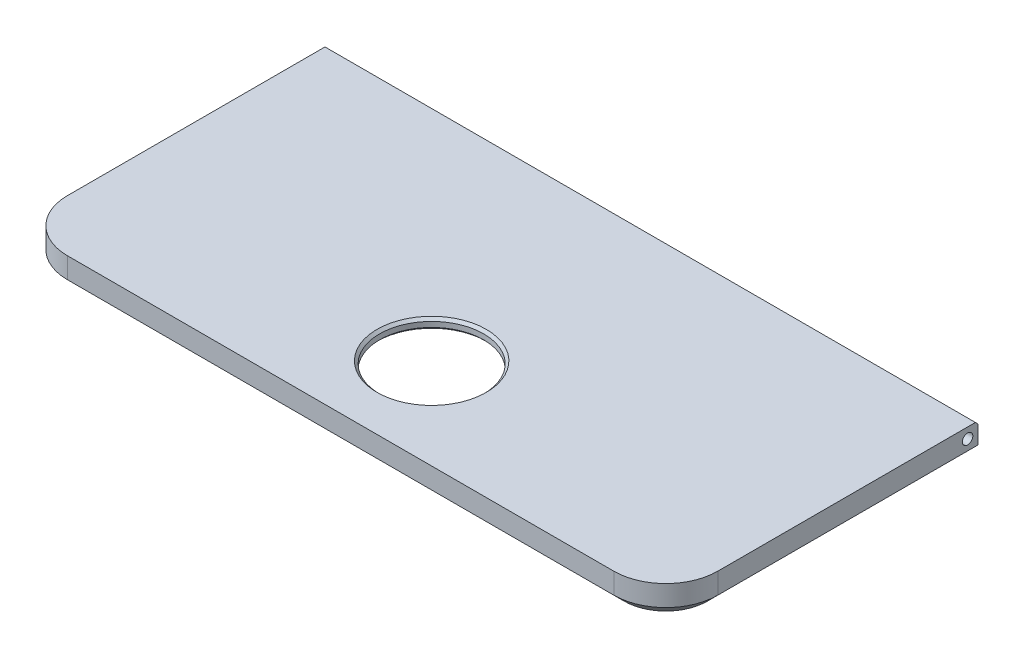
from build123d import *

# Parameters (mm, degrees)
SKETCH_1_W          = 125
SKETCH_1_H          = 60
EXTRUDE_1_DEPTH     = 6
FILLET_1_R          = 10
CUT_EXTRUDE_1_DEPTH = 4
CHAMFER_1_SIZE      = 2
SKETCH_4_W          = 118
SKETCH_4_H          = 1.5
EXTRUDE_3_DEPTH     = 4
SKETCH_3_R          = 1
CUT_EXTRUDE_2_DEPTH = 10
SKETCH_5_R          = 1
CUT_EXTRUDE_3_DEPTH = 10
SKETCH_6_R          = 10
CUT_EXTRUDE_4_DEPTH = 2
CHAMFER_2_SIZE      = 0.5


with BuildPart() as part:
    # Эскиз1 → Бобышка-Вытянуть1 (new body)
    with BuildSketch(Plane(origin=(0, 0, 0), x_dir=(1, 0, 0), z_dir=(0, 1, 0))):
        Rectangle(SKETCH_1_W, SKETCH_1_H)
    extrude(amount=EXTRUDE_1_DEPTH)

    # Скругление1
    fillet_1_edges = [part.edges().sort_by_distance(p)[0] for p in [
        (62.5, 3, 30),
        (-62.5, 3, 30),
    ]]
    fillet(fillet_1_edges, radius=FILLET_1_R)

    # Эскиз2 → Вырез-Вытянуть1 (cut)
    with BuildSketch(Plane.XZ):
        with BuildLine():
            Line((-59, 20), (-59, -26.5))
            Line((-59, -26.5), (59, -26.5))
            Line((59, -26.5), (59, 20))
            ThreePointArc((59, 20), (57.096194078, 24.596194078), (52.5, 26.5))
            Line((52.5, 26.5), (-52.5, 26.5))
            ThreePointArc((-52.5, 26.5), (-57.096194078, 24.596194078), (-59, 20))
        make_face()
    extrude(amount=-CUT_EXTRUDE_1_DEPTH, mode=Mode.SUBTRACT)

    # Фаска1
    chamfer_1_edges = [part.edges().sort_by_distance(p)[0] for p in [
        (0, 0, 30),
        (62.5, 0, -5),
        (59.571067812, 0, 27.071067812),
        (-59.571067812, 0, 27.071067812),
        (-62.5, 0, -5),
        (0, 0, -30),
    ]]
    chamfer(chamfer_1_edges, length=CHAMFER_1_SIZE)

    # Эскиз4 → Бобышка-Вытянуть3 (add)
    with BuildSketch(Plane.XZ.offset(-4)):
        with Locations((0, -25.75)):
            Rectangle(SKETCH_4_W, SKETCH_4_H)
    extrude(amount=EXTRUDE_3_DEPTH)

    # Эскиз3 → Вырез-Вытянуть2 (cut)
    with BuildSketch(Plane(origin=(62.5, 0, 0), x_dir=(0, 0, -1), z_dir=(1, 0, 0))):
        with Locations((28, 4)):
            Circle(SKETCH_3_R)
    extrude(amount=-CUT_EXTRUDE_2_DEPTH, mode=Mode.SUBTRACT)

    # Эскиз5 → Вырез-Вытянуть3 (cut)
    with BuildSketch(Plane.ZY.offset(62.5)):
        with Locations((-28, 4)):
            Circle(SKETCH_5_R)
    extrude(amount=-CUT_EXTRUDE_3_DEPTH, mode=Mode.SUBTRACT)

    # Эскиз6 → Вырез-Вытянуть4 (cut)
    with BuildSketch(Plane.XZ.offset(-4)):
        with Locations((0, 12.5)):
            Circle(SKETCH_6_R)
    extrude(amount=-CUT_EXTRUDE_4_DEPTH, mode=Mode.SUBTRACT)

    # Фаска2
    chamfer_2_edges = [part.edges().sort_by_distance(p)[0] for p in [
        (0, 6, -30),
        (-10, 4, 12.5),
        (-10, 6, 12.5),
    ]]
    chamfer(chamfer_2_edges, length=CHAMFER_2_SIZE)


solid = part.part
